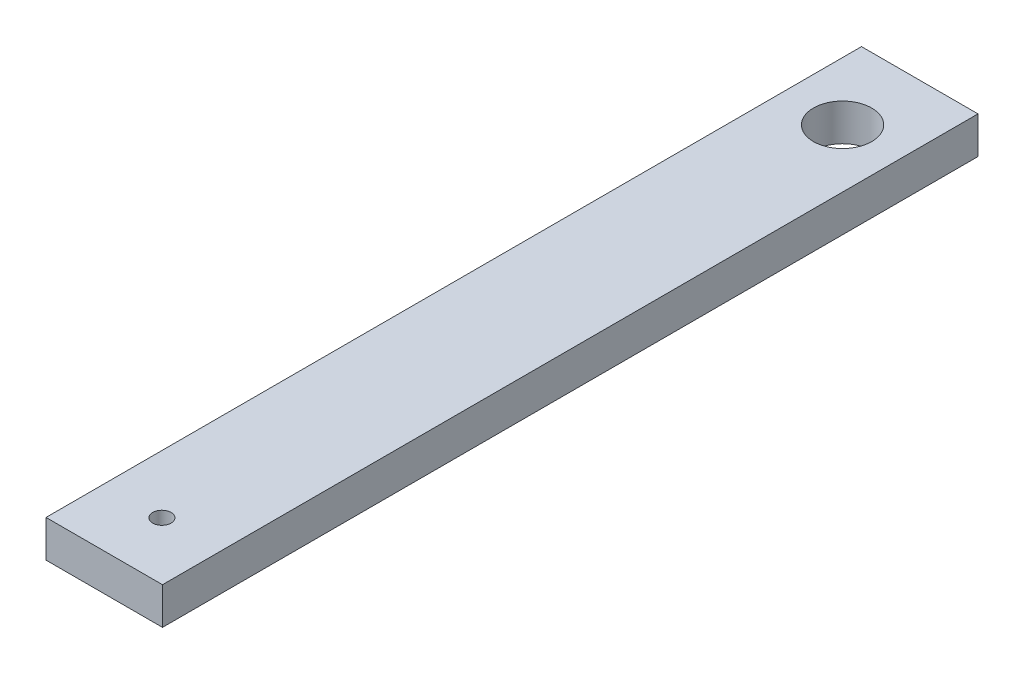
from build123d import *

# Parameters (mm, degrees)
SKETCH1_W           = 20
SKETCH1_H           = 140
SKETCH1_R           = 5
SKETCH1_R_2         = 1.5875
BOSS_EXTRUDE1_DEPTH = 6.35


with BuildPart() as part:
    # Sketch1 → Boss-Extrude1 (new body)
    with BuildSketch(Plane(origin=(0, 0, 0), x_dir=(1, 0, 0), z_dir=(0, 1, 0))):
        with Locations((0, 6.625)):
            Rectangle(SKETCH1_W, SKETCH1_H)
        with Locations((0, 63.375)):
            Circle(SKETCH1_R, mode=Mode.SUBTRACT)
        with Locations((0, -53.477664451)):
            Circle(SKETCH1_R_2, mode=Mode.SUBTRACT)
    extrude(amount=BOSS_EXTRUDE1_DEPTH)


solid = part.part
